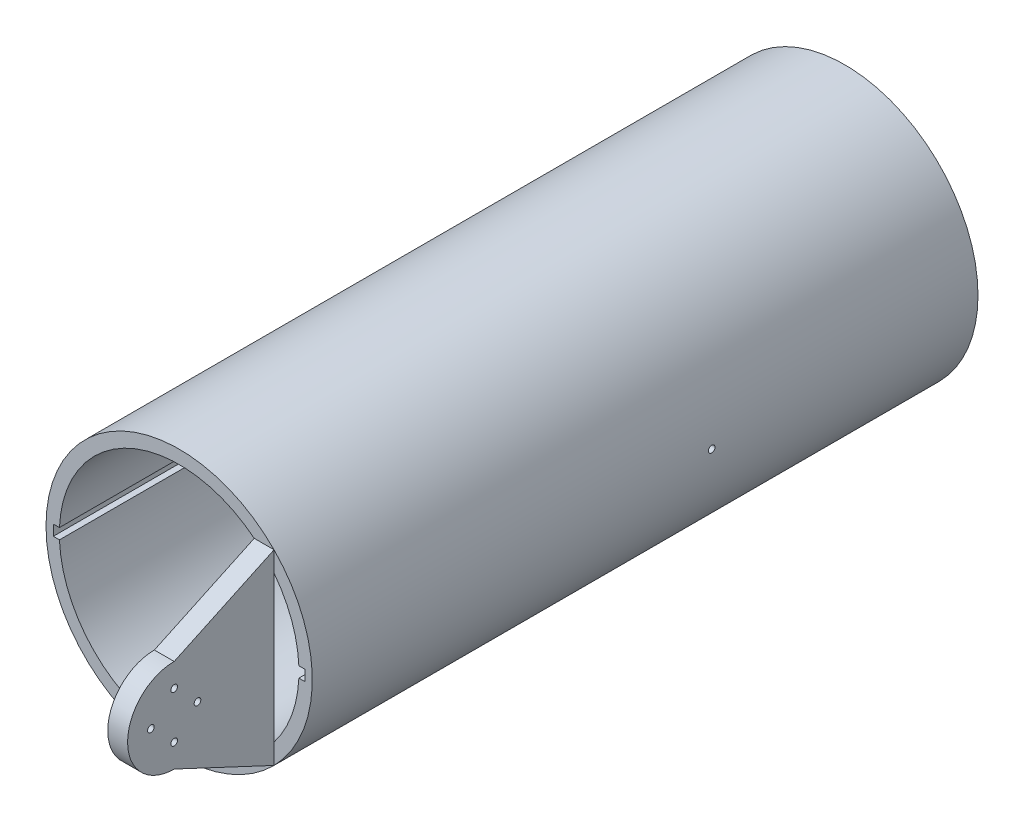
from build123d import *

# Parameters (mm, degrees)
SKETCH1_R               = 50
BOSS_EXTRUDE1_DEPTH     = 250
BOSS_EXTRUDE2_DEPTH     = 55
SKETCH7_R               = 1.25
CUT_EXTRUDE4_DEPTH      = 75
CUT_EXTRUDE4_DEPTH_BACK = 96
CUT_EXTRUDE5_DEPTH      = 96
CUT_EXTRUDE6_DEPTH      = 96
SKETCH10_R              = 1.25
CUT_EXTRUDE7_DEPTH      = 96


with BuildPart() as part:
    # Sketch1 → Boss-Extrude1 (new body)
    with BuildSketch(Plane.XY):
        Circle(SKETCH1_R)
        with BuildLine():
            Line((-44.955555556, 1.999506112), (-47.255555556, 1.999506112))
            Line((-47.255555556, 1.999506112), (-47.255555556, -1.999506112))
            Line((-47.255555556, -1.999506112), (-44.955555556, -1.999506112))
            ThreePointArc((-44.955555556, -1.999506112), (0, -45), (44.955555556, -1.999506112))
            Line((44.955555556, -1.999506112), (47.255555556, -1.999506112))
            Line((47.255555556, -1.999506112), (47.255555556, 1.999506112))
            Line((47.255555556, 1.999506112), (44.955555556, 1.999506112))
            ThreePointArc((44.955555556, 1.999506112), (0, 45), (-44.955555556, 1.999506112))
        make_face(mode=Mode.SUBTRACT)
    extrude(amount=BOSS_EXTRUDE1_DEPTH)

    # Sketch3 → Boss-Extrude2 (add)
    with BuildSketch(Plane.XY.offset(250)):
        Polygon((28.2, 0), (28.2, 35.067934071), (35.640426485, 35.067934071), (35.640426485, -35.067934071), (28.2, -35.067934071), align=None)
    extrude(amount=BOSS_EXTRUDE2_DEPTH)

    # Sketch7 → Cut-Extrude4 (cut, two sides)
    with BuildSketch(Plane(origin=(35.640426485, 0, 0), x_dir=(0, 0, -1), z_dir=(1, 0, 0))) as cut_extrude4_sk:
        with Locations((-100, 0)):
            Circle(SKETCH7_R)
    extrude(amount=CUT_EXTRUDE4_DEPTH, mode=Mode.SUBTRACT)
    extrude(cut_extrude4_sk.sketch, amount=-CUT_EXTRUDE4_DEPTH_BACK, mode=Mode.SUBTRACT)

    # Sketch8 → Cut-Extrude5 (cut)
    with BuildSketch(Plane(origin=(35.640426485, 0, 0), x_dir=(0, 0, -1), z_dir=(1, 0, 0))):
        with BuildLine():
            Line((-287.5, 17.5), (-250, 35.067934071))
            Line((-250, 35.067934071), (-305, 35.067934071))
            Line((-305, 35.067934071), (-305, 0))
            ThreePointArc((-305, 0), (-299.874368671, 12.374368671), (-287.5, 17.5))
        make_face()
    extrude(amount=-CUT_EXTRUDE5_DEPTH, mode=Mode.SUBTRACT)

    # Sketch9 → Cut-Extrude6 (cut)
    with BuildSketch(Plane(origin=(35.640426485, 0, 0), x_dir=(0, 0, -1), z_dir=(1, 0, 0))):
        with BuildLine():
            Line((-287.5, -17.5), (-250, -35.067934071))
            Line((-250, -35.067934071), (-305, -35.067934071))
            Line((-305, -35.067934071), (-305, 0))
            ThreePointArc((-305, 0), (-299.874368671, -12.374368671), (-287.5, -17.5))
        make_face()
    extrude(amount=-CUT_EXTRUDE6_DEPTH, mode=Mode.SUBTRACT)

    # Sketch10 → Cut-Extrude7 (cut)
    with BuildSketch(Plane(origin=(35.640426485, 0, 0), x_dir=(0, 0, -1), z_dir=(1, 0, 0))):
        with Locations((-296.25, 0)):
            Circle(SKETCH10_R)
        with Locations((-287.5, 8.75)):
            Circle(SKETCH10_R)
        with Locations((-278.75, 0)):
            Circle(SKETCH10_R)
        with Locations((-287.5, -8.75)):
            Circle(SKETCH10_R)
    extrude(amount=-CUT_EXTRUDE7_DEPTH, mode=Mode.SUBTRACT)


solid = part.part
